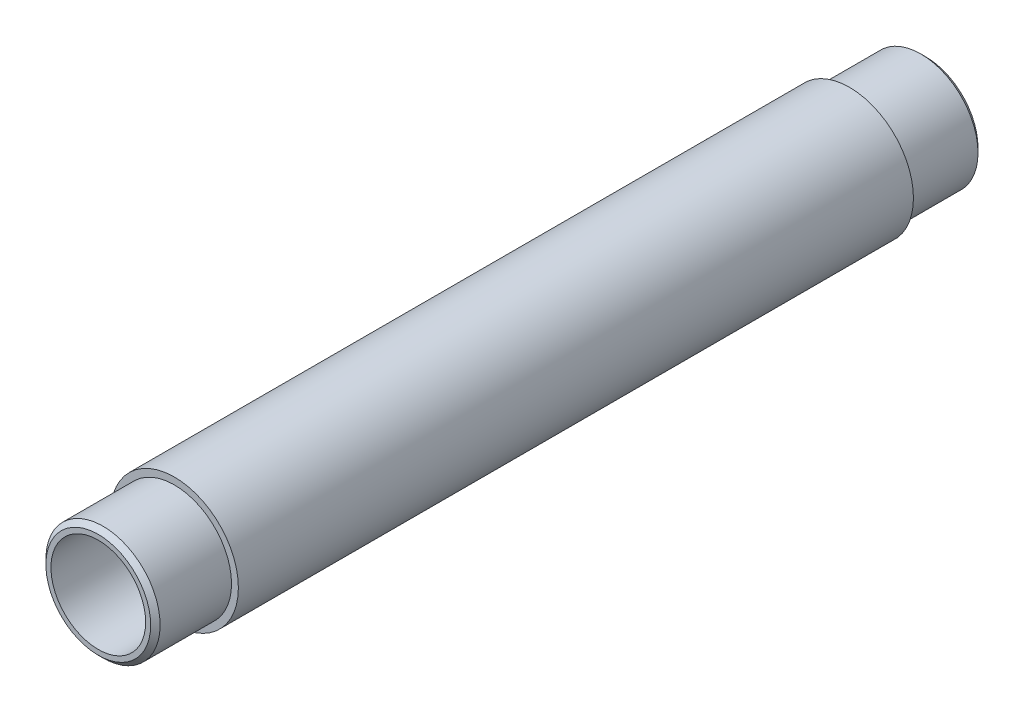
from build123d import *

# Parameters (mm, degrees)
BOSS_EXTRUDE1_DEPTH      = 69
BOSS_EXTRUDE1_DEPTH_BACK = 69
SKETCH1_R                = 10.668
SKETCH1_R_2              = 7.8994
SKETCH2_R                = 15.23227921
SKETCH2_R_2              = 9.525
CUT_EXTRUDE1_DEPTH       = 12.7
CUT_EXTRUDE2_START       = -12.7
SKETCH3_R                = 15.23227921
SKETCH3_R_2              = 9.525
CUT_EXTRUDE2_DEPTH       = 12.7
CHAMFER1_SIZE            = 0.7874


with BuildPart() as part:
    # Sketch1 → Boss-Extrude1 (new, two sides: drawn at the far end of the back side and taken through both)
    with BuildSketch(Plane.XY.offset(-BOSS_EXTRUDE1_DEPTH_BACK)):
        Circle(SKETCH1_R)
        Circle(SKETCH1_R_2, mode=Mode.SUBTRACT)
    extrude(amount=BOSS_EXTRUDE1_DEPTH + BOSS_EXTRUDE1_DEPTH_BACK)

    # Sketch2 → Cut-Extrude1 (cut)
    with BuildSketch(Plane.XY.offset(69)):
        Circle(SKETCH2_R)
        Circle(SKETCH2_R_2, mode=Mode.SUBTRACT)
    extrude(amount=-CUT_EXTRUDE1_DEPTH, mode=Mode.SUBTRACT)

    # Sketch3 → Cut-Extrude2 (cut)
    with BuildSketch(Plane(origin=(0, 0, -69), x_dir=(-1, 0, 0), z_dir=(0, 0, -1)).offset(CUT_EXTRUDE2_START)):
        Circle(SKETCH3_R)
        Circle(SKETCH3_R_2, mode=Mode.SUBTRACT)
    extrude(amount=CUT_EXTRUDE2_DEPTH, mode=Mode.SUBTRACT)

    # Chamfer1
    chamfer1_edges = [part.edges().sort_by_distance(p)[0] for p in [
        (-9.525, 0, 69),
        (9.525, 0, -69),
    ]]
    chamfer(chamfer1_edges, length=CHAMFER1_SIZE)


solid = part.part
